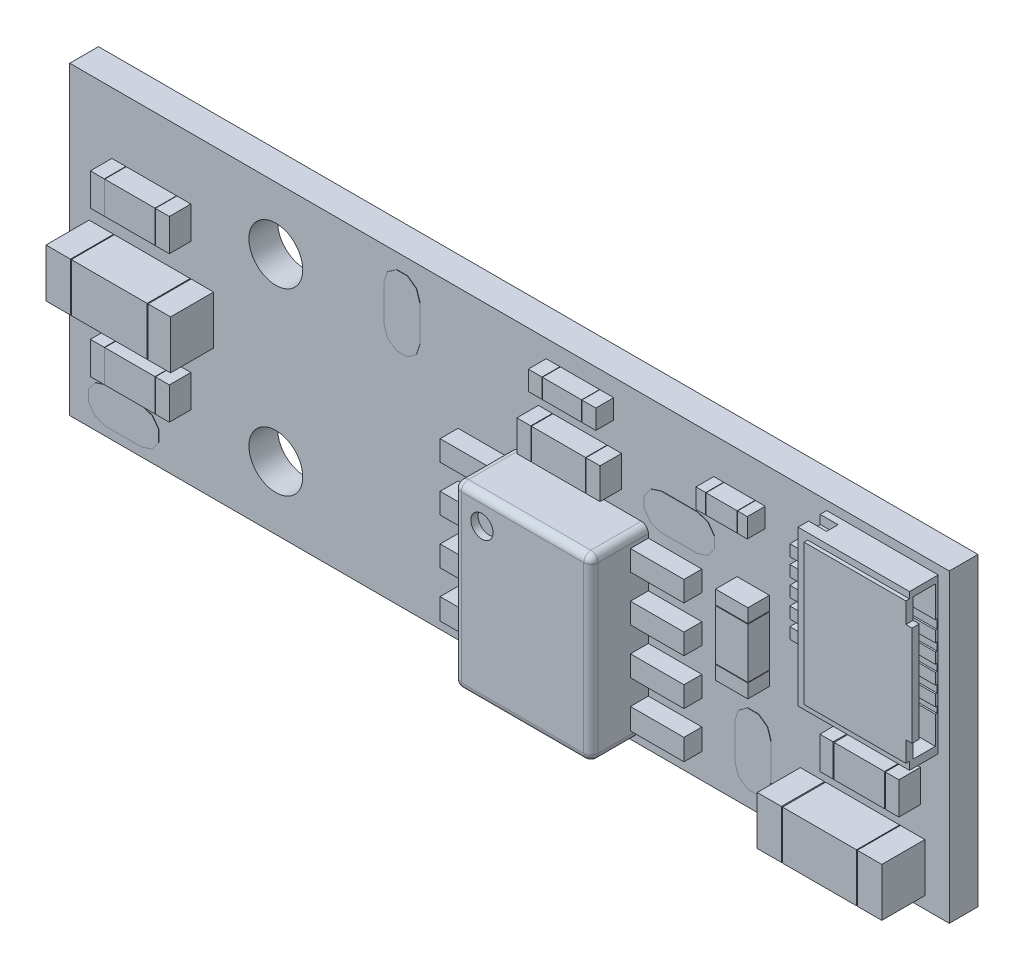
from build123d import *

# Parameters (mm, degrees)
SKETCH_4_W          = 24.5
SKETCH_4_H          = 8.5
EXTRUDE_1_DEPTH     = 0.8
SKETCH_5_W          = 1.4000508
SKETCH_5_H          = 0.9
SKETCH_5_W_2        = 1.508763018
SKETCH_5_H_2        = 0.863601728
SKETCH_5_W_3        = 0.9
SKETCH_5_H_3        = 1.4000508
EXTRUDE_2_DEPTH     = 0.6
SKETCH_7_W          = 0.38936644
SKETCH_7_H          = 0.9
SKETCH_7_W_2        = 0.386965166
SKETCH_7_W_3        = 0.374412652
SKETCH_7_W_4        = 0.369313641
SKETCH_7_W_5        = 0.38743017
SKETCH_7_H_2        = 0.863601728
SKETCH_7_W_6        = 0.392233703
SKETCH_7_W_7        = 0.9
SKETCH_7_H_3        = 0.383985009
SKETCH_7_H_4        = 0.380482222
EXTRUDE_4_DEPTH     = 0.6
SKETCH_8_W          = 2.111480823
SKETCH_8_H          = 1.351282702
SKETCH_8_W_2        = 2.059944119
EXTRUDE_5_DEPTH     = 1.2
SKETCH_9_W          = 0.682150033
SKETCH_9_H          = 1.351282702
SKETCH_9_W_2        = 0.626545069
SKETCH_9_W_3        = 0.672983259
SKETCH_9_W_4        = 0.682233584
EXTRUDE_6_DEPTH     = 1.2
SKETCH_10_W         = 1.09017018
SKETCH_10_H         = 0.54000508
SKETCH_10_W_2       = 0.865633732
EXTRUDE_7_DEPTH     = 0.5
SKETCH_11_W         = 0.383213851
SKETCH_11_H         = 0.54000508
SKETCH_11_W_2       = 0.386964973
SKETCH_11_W_3       = 0.271682559
SKETCH_11_W_4       = 0.272230671
EXTRUDE_8_DEPTH     = 0.5
SKETCH_12_W         = 3.81000762
SKETCH_12_H         = 4.998729998
EXTRUDE_9_DEPTH     = 1.6
SKETCH_13_W         = 1.490982982
SKETCH_13_H         = 0.56791902
SKETCH_13_H_2       = 0.571840052
SKETCH_13_H_3       = 0.576211596
SKETCH_13_H_4       = 0.589959728
EXTRUDE_10_DEPTH    = 0.5
SKETCH_14_R         = 0.309441582
CUT_EXTRUDE_1_DEPTH = 0.2
SKETCH_15_W         = 3.105156211
SKETCH_15_H         = 4.314198628
EXTRUDE_11_DEPTH    = 0.8
SKETCH_16_W         = 0.728981457
SKETCH_16_H         = 0.312621285
SKETCH_16_H_2       = 0.301573575
SKETCH_16_H_3       = 0.296607298
SKETCH_16_H_4       = 0.314929508
SKETCH_16_H_5       = 0.304042001
EXTRUDE_12_DEPTH    = 0.3
SKETCH_17_W         = 0.321385543
SKETCH_17_H         = 0.24963067
SKETCH_17_H_2       = 0.24483409
CUT_EXTRUDE_2_DEPTH = 0.5
SKETCH_18_W         = 0.881970951
SKETCH_18_H         = 3.917133554
CUT_EXTRUDE_3_DEPTH = 2.5
SKETCH_19_W         = 0.627756862
SKETCH_19_H         = 0.17571207
SKETCH_19_H_2       = 0.211616774
SKETCH_19_H_3       = 0.195591839
SKETCH_19_H_4       = 0.217055344
SKETCH_19_H_5       = 0.249361414
CUT_EXTRUDE_4_DEPTH = 2.8
EXTRUDE_13_DEPTH    = 0.1
EXTRUDE_14_DEPTH    = 0.01
FILLET_1_R          = 0.2
SKETCH_24_R         = 0.75
CUT_EXTRUDE_5_DEPTH = 1.8


with BuildPart() as part:
    # 草图4 → 凸台-拉伸1 (new body)
    with BuildSketch(Plane.XY):
        with Locations((12.25, 4.25)):
            Rectangle(SKETCH_4_W, SKETCH_4_H)
    extrude(amount=EXTRUDE_1_DEPTH)

    # 草图5 → 凸台-拉伸2 (add)
    with BuildSketch(Plane.XY.offset(0.8)):
        with Locations((2.27495555, 6.340995682)):
            Rectangle(SKETCH_5_W, SKETCH_5_H)
        with Locations((2.27495555, 2.276987554)):
            Rectangle(SKETCH_5_W, SKETCH_5_H)
        with Locations((14.212979426, 6.340995682)):
            Rectangle(SKETCH_5_W_2, SKETCH_5_H_2)
        with Locations((22.59499619, 2.911988824)):
            Rectangle(SKETCH_5_W, SKETCH_5_H)
        with Locations((19.038989078, 4.308991618)):
            Rectangle(SKETCH_5_W_3, SKETCH_5_H_3)
    extrude(amount=EXTRUDE_2_DEPTH)

    # 草图7 → 凸台-拉伸4 (add)
    with BuildSketch(Plane.XY.offset(0.8)):
        with Locations((3.18029773, 6.340995682)):
            Rectangle(SKETCH_7_W, SKETCH_7_H)
        with Locations((1.368412733, 6.340995682)):
            Rectangle(SKETCH_7_W_2, SKETCH_7_H)
        with Locations((3.18029773, 2.276987554)):
            Rectangle(SKETCH_7_W, SKETCH_7_H)
        with Locations((1.368412733, 2.276987554)):
            Rectangle(SKETCH_7_W_2, SKETCH_7_H)
        with Locations((23.507815264, 2.911988824)):
            Rectangle(SKETCH_7_W_3, SKETCH_7_H)
        with Locations((21.67962761, 2.911988824)):
            Rectangle(SKETCH_7_W_4, SKETCH_7_H)
        with Locations((13.248452194, 6.340995682)):
            Rectangle(SKETCH_7_W_5, SKETCH_7_H_2)
        with Locations((15.175104891, 6.340995682)):
            Rectangle(SKETCH_7_W_6, SKETCH_7_H_2)
        with Locations((19.038989078, 3.400958723)):
            Rectangle(SKETCH_7_W_7, SKETCH_7_H_3)
        with Locations((19.038989078, 5.218775907)):
            Rectangle(SKETCH_7_W_7, SKETCH_7_H_4)
    extrude(amount=EXTRUDE_4_DEPTH)

    # 草图8 → 凸台-拉伸5 (add)
    with BuildSketch(Plane.XY.offset(0.8)):
        with Locations((2.299453899, 4.308991618)):
            Rectangle(SKETCH_8_W, SKETCH_8_H)
        with Locations((22.085725172, 1.006985014)):
            Rectangle(SKETCH_8_W_2, SKETCH_8_H)
    extrude(amount=EXTRUDE_5_DEPTH)

    # 草图9 → 凸台-拉伸6 (add)
    with BuildSketch(Plane.XY.offset(0.8)):
        with Locations((0.879937095, 4.308991618)):
            Rectangle(SKETCH_9_W, SKETCH_9_H)
        with Locations((3.695236483, 4.308991618)):
            Rectangle(SKETCH_9_W_2, SKETCH_9_H)
        with Locations((20.687393332, 1.006985014)):
            Rectangle(SKETCH_9_W_3, SKETCH_9_H)
        with Locations((23.479431849, 1.006985014)):
            Rectangle(SKETCH_9_W_4, SKETCH_9_H)
    extrude(amount=EXTRUDE_6_DEPTH)

    # 草图10 → 凸台-拉伸7 (add)
    with BuildSketch(Plane.XY.offset(0.8)):
        with Locations((14.212979426, 7.737998476)):
            Rectangle(SKETCH_10_W, SKETCH_10_H)
        with Locations((18.657988316, 7.22999746)):
            Rectangle(SKETCH_10_W_2, SKETCH_10_H)
    extrude(amount=EXTRUDE_7_DEPTH)

    # 草图11 → 凸台-拉伸8 (add)
    with BuildSketch(Plane.XY.offset(0.8)):
        with Locations((13.464454272, 7.737998476)):
            Rectangle(SKETCH_11_W, SKETCH_11_H)
        with Locations((14.959629019, 7.737998476)):
            Rectangle(SKETCH_11_W_2, SKETCH_11_H)
        with Locations((18.078183165, 7.22999746)):
            Rectangle(SKETCH_11_W_3, SKETCH_11_H)
        with Locations((19.237519412, 7.22999746)):
            Rectangle(SKETCH_11_W_4, SKETCH_11_H)
    extrude(amount=EXTRUDE_8_DEPTH)

    # 草图12 → 凸台-拉伸9 (add)
    with BuildSketch(Plane.XY.offset(0.8)):
        with Locations((14.212979426, 2.911988824)):
            Rectangle(SKETCH_12_W, SKETCH_12_H)
    extrude(amount=EXTRUDE_9_DEPTH)

    # 草图13 → 凸台-拉伸10 (add)
    with BuildSketch(Plane.XY.offset(0.8)):
        with Locations((11.562484125, 4.817513693)):
            Rectangle(SKETCH_13_W, SKETCH_13_H)
        with Locations((11.562484125, 3.545550637)):
            Rectangle(SKETCH_13_W, SKETCH_13_H_2)
        with Locations((11.562484125, 2.273362325)):
            Rectangle(SKETCH_13_W, SKETCH_13_H_3)
        with Locations((11.562484125, 0.996485719)):
            Rectangle(SKETCH_13_W, SKETCH_13_H_4)
        with Locations((16.863474727, 0.996485719)):
            Rectangle(SKETCH_13_W, SKETCH_13_H_4)
        with Locations((16.863474727, 2.273362325)):
            Rectangle(SKETCH_13_W, SKETCH_13_H_3)
        with Locations((16.863474727, 3.545550637)):
            Rectangle(SKETCH_13_W, SKETCH_13_H_2)
        with Locations((16.863474727, 4.817513693)):
            Rectangle(SKETCH_13_W, SKETCH_13_H)
    extrude(amount=EXTRUDE_10_DEPTH)

    # 草图14 → 切除-拉伸1 (cut)
    with BuildSketch(Plane.XY.offset(2.4)):
        with Locations((13.082879749, 4.668398252)):
            Circle(SKETCH_14_R)
    extrude(amount=-CUT_EXTRUDE_1_DEPTH, mode=Mode.SUBTRACT)

    # 草图15 → 凸台-拉伸11 (add)
    with BuildSketch(Plane.XY.offset(0.8)):
        with Locations((22.638811278, 6.093980188)):
            Rectangle(SKETCH_15_W, SKETCH_15_H)
    extrude(amount=EXTRUDE_11_DEPTH)

    # 草图16 → 凸台-拉伸12 (add)
    with BuildSketch(Plane.XY.offset(0.8)):
        with Locations((20.721742443, 7.081306833)):
            Rectangle(SKETCH_16_W, SKETCH_16_H)
        with Locations((20.721742443, 6.586449686)):
            Rectangle(SKETCH_16_W, SKETCH_16_H_2)
        with Locations((20.721742443, 6.088551825)):
            Rectangle(SKETCH_16_W, SKETCH_16_H_3)
        with Locations((20.721742443, 5.579009719)):
            Rectangle(SKETCH_16_W, SKETCH_16_H_4)
        with Locations((20.721742443, 5.084072472)):
            Rectangle(SKETCH_16_W, SKETCH_16_H_5)
    extrude(amount=EXTRUDE_12_DEPTH)

    # 草图17 → 切除-拉伸2 (cut)
    with BuildSketch(Plane.ZY.offset(-21.086233172)):
        with Locations((1.143696237, 4.061696209)):
            Rectangle(SKETCH_17_W, SKETCH_17_H)
        with Locations((1.143696237, 8.128662457)):
            Rectangle(SKETCH_17_W, SKETCH_17_H_2)
    extrude(amount=-CUT_EXTRUDE_2_DEPTH, mode=Mode.SUBTRACT)

    # 草图18 → 切除-拉伸3 (cut)
    with BuildSketch(Plane(origin=(24.191389383, 0, 0), x_dir=(0, 0, -1), z_dir=(1, 0, 0))):
        with Locations((-1.3215992, 6.11557541)):
            Rectangle(SKETCH_18_W, SKETCH_18_H)
    extrude(amount=-CUT_EXTRUDE_3_DEPTH, mode=Mode.SUBTRACT)

    # 草图19 → 切除-拉伸4 (cut)
    with BuildSketch(Plane(origin=(24.191389383, 0, 0), x_dir=(0, 0, -1), z_dir=(1, 0, 0))):
        with Locations((-1.1495481, 5.019907506)):
            Rectangle(SKETCH_19_W, SKETCH_19_H)
        with Locations((-1.1495481, 5.527353352)):
            Rectangle(SKETCH_19_W, SKETCH_19_H_2)
        with Locations((-1.1495481, 6.038044096)):
            Rectangle(SKETCH_19_W, SKETCH_19_H_3)
        with Locations((-1.1495481, 6.544190571)):
            Rectangle(SKETCH_19_W, SKETCH_19_H_4)
        with Locations((-1.1495481, 7.084675627)):
            Rectangle(SKETCH_19_W, SKETCH_19_H_5)
    extrude(amount=-CUT_EXTRUDE_4_DEPTH, mode=Mode.SUBTRACT)

    # 草图20 → 凸台-拉伸13 (add, symmetric)
    with BuildSketch(Plane.XY.offset(1.6)):
        Polygon((24.191389383, 4.157008633), (24.191389383, 4.724075652), (24.362434909, 4.724075652), (24.362434909, 7.504550233), (24.191389383, 7.504550233), (24.191389383, 8.074142187), (21.355727488, 8.074142187), (21.355727488, 4.157008633), align=None)
    extrude(amount=EXTRUDE_13_DEPTH, both=True)

    # 草图21 → 凸台-拉伸14 (add)
    with BuildSketch(Plane.XY.offset(0.8)):
        Polygon((19.444327923, 0.625482504), (19.539819669, 0.919375876), (19.539819669, 1.919378416), (19.444327923, 2.213271789), (19.194327288, 2.394907882), (18.885309509, 2.394907882), (18.635308874, 2.213271789), (18.539817129, 1.919378416), (18.539817129, 0.919375876), (18.635308874, 0.625482504), (18.885309509, 0.44384641), (19.194327288, 0.44384641), align=None)
        Polygon((16.48877733, 6.424863275), (16.194883957, 6.32937153), (16.013247864, 6.079370895), (16.013247864, 5.770353116), (16.194883957, 5.520352481), (16.48877733, 5.424860735), (17.48877987, 5.424860735), (17.782673243, 5.520352481), (17.964309336, 5.770353116), (17.964309336, 6.079370895), (17.782673243, 6.32937153), (17.48877987, 6.424863275), align=None)
        Polygon((9.664479045, 6.309102563), (9.75997079, 6.602995936), (9.75997079, 7.602998476), (9.664479045, 7.896891849), (9.41447841, 8.078527942), (9.10546063, 8.078527942), (8.855459995, 7.896891849), (8.75996825, 7.602998476), (8.75996825, 6.602995936), (8.855459995, 6.309102563), (9.10546063, 6.12746647), (9.41447841, 6.12746647), align=None)
        Polygon((1.012952756, 1.252985776), (0.719059383, 1.157494031), (0.53742329, 0.907493396), (0.53742329, 0.598475616), (0.719059383, 0.348474981), (1.012952756, 0.252983236), (2.012955296, 0.252983236), (2.306848669, 0.348474981), (2.488484762, 0.598475616), (2.488484762, 0.907493396), (2.306848669, 1.157494031), (2.012955296, 1.252985776), align=None)
    extrude(amount=EXTRUDE_14_DEPTH)

    # 圆角1
    fillet_1_edges = [part.edges().sort_by_distance(p)[0] for p in [
        (12.307975616, 5.411353823, 1.6),
        (12.307975616, 0.412623825, 1.6),
        (16.117983236, 0.412623825, 1.6),
        (16.117983236, 5.411353823, 1.6),
        (12.307975616, 2.911988824, 2.4),
        (14.212979426, 0.412623825, 2.4),
        (16.117983236, 2.911988824, 2.4),
        (14.212979426, 5.411353823, 2.4),
    ]]
    fillet(fillet_1_edges, radius=FILLET_1_R)

    # 草图24 → 切除-拉伸5 (cut, through all)
    with BuildSketch(Plane.XY.offset(0.8)):
        with Locations((5.740962662, 6.762997206)):
            Circle(SKETCH_24_R)
        with Locations((5.740962662, 1.762987046)):
            Circle(SKETCH_24_R)
    extrude(amount=-CUT_EXTRUDE_5_DEPTH, mode=Mode.SUBTRACT)


solid = part.part
